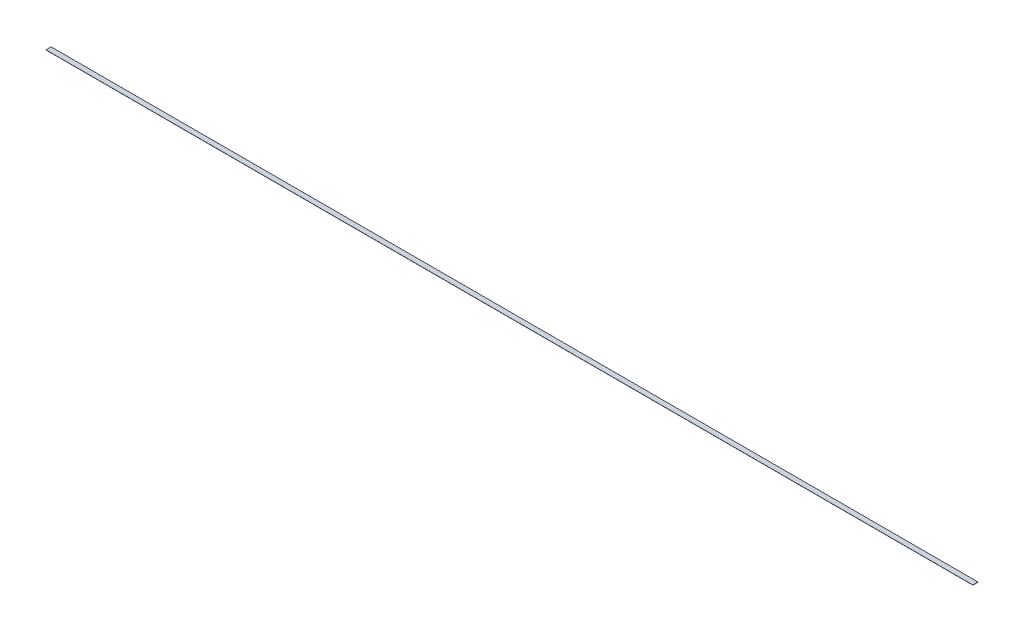
from build123d import *

# Parameters (mm, degrees)
SKETCH1_W           = 9144
SKETCH1_H           = 50.8
BOSS_EXTRUDE1_DEPTH = 1.5875


with BuildPart() as part:
    # Sketch1 → Boss-Extrude1 (new body)
    with BuildSketch(Plane(origin=(0, 0, 0), x_dir=(1, 0, 0), z_dir=(0, 1, 0))):
        with Locations((4572, 25.4)):
            Rectangle(SKETCH1_W, SKETCH1_H)
    extrude(amount=BOSS_EXTRUDE1_DEPTH)


solid = part.part
